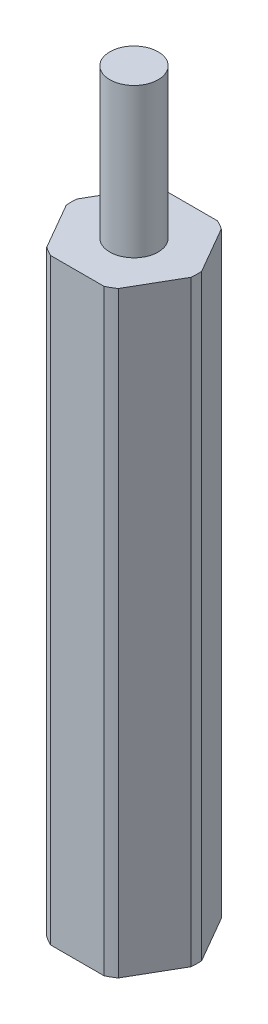
from build123d import *

# Parameters (mm, degrees)
BOSS_EXTRUDE1_DEPTH = 25.4
SKETCH2_R           = 1.0287
BOSS_EXTRUDE2_DEPTH = 6.35
SKETCH3_R           = 1.0287
CUT_EXTRUDE1_DEPTH  = 6.35


with BuildPart() as part:
    # Sketch1 → Boss-Extrude1 (new body)
    with BuildSketch(Plane(origin=(0, 0, 0), x_dir=(1, 0, 0), z_dir=(0, 1, 0))):
        with BuildLine():
            Line((-1.135922533, 2.413), (1.135922533, 2.413))
            ThreePointArc((1.135922533, 2.413), (1.3335, 2.309689752), (1.521758033, 2.19023777))
            Line((1.521758033, 2.19023777), (2.657680566, 0.22276223))
            ThreePointArc((2.657680566, 0.22276223), (2.667, 0), (2.657680566, -0.22276223))
            Line((2.657680566, -0.22276223), (1.521758033, -2.19023777))
            ThreePointArc((1.521758033, -2.19023777), (1.3335, -2.309689752), (1.135922533, -2.413))
            Line((1.135922533, -2.413), (-1.135922533, -2.413))
            ThreePointArc((-1.135922533, -2.413), (-1.3335, -2.309689752), (-1.521758033, -2.19023777))
            Line((-1.521758033, -2.19023777), (-2.657680566, -0.22276223))
            ThreePointArc((-2.657680566, -0.22276223), (-2.667, 0), (-2.657680566, 0.22276223))
            Line((-2.657680566, 0.22276223), (-1.521758033, 2.19023777))
            ThreePointArc((-1.521758033, 2.19023777), (-1.3335, 2.309689752), (-1.135922533, 2.413))
        make_face()
    extrude(amount=BOSS_EXTRUDE1_DEPTH)

    # Sketch2 → Boss-Extrude2 (add)
    with BuildSketch(Plane(origin=(0, 25.4, 0), x_dir=(1, 0, 0), z_dir=(0, 1, 0))):
        Circle(SKETCH2_R)
    extrude(amount=BOSS_EXTRUDE2_DEPTH)

    # Sketch3 → Cut-Extrude1 (cut)
    with BuildSketch(Plane.XZ):
        Circle(SKETCH3_R)
    extrude(amount=-CUT_EXTRUDE1_DEPTH, mode=Mode.SUBTRACT)


solid = part.part
